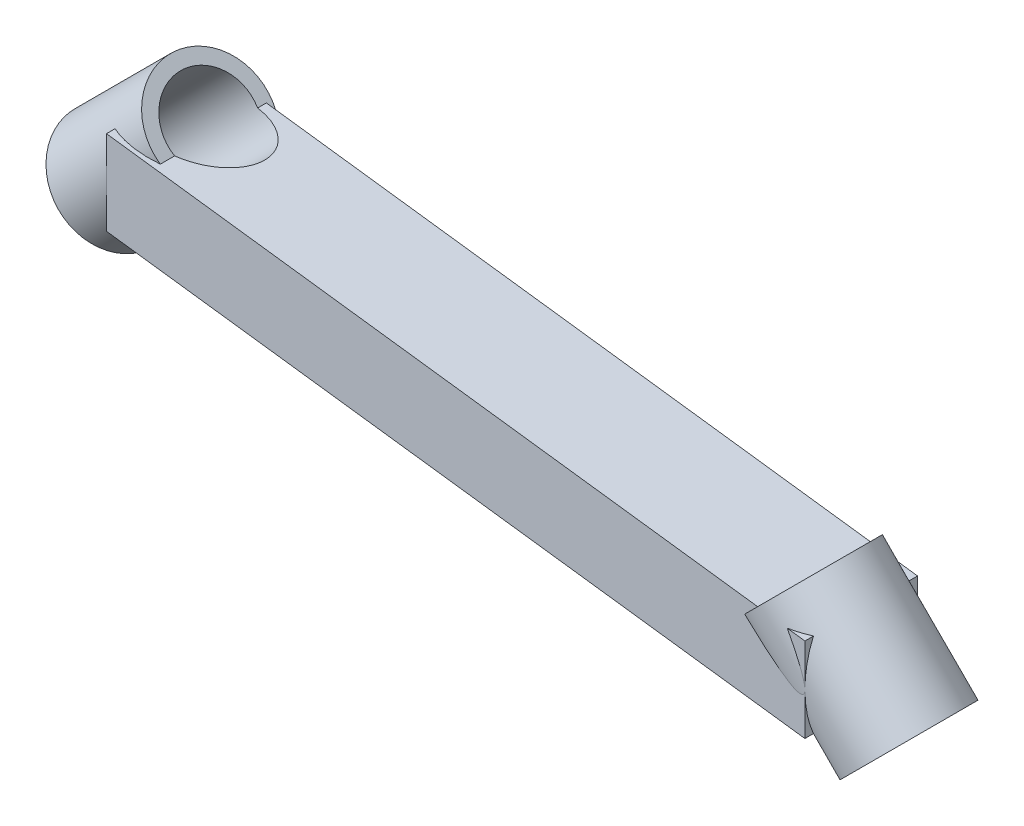
from build123d import *
from build123d.topology import SkipClean

# Parameters (mm, degrees)
BOSS_EXTRUDE1_DEPTH     = 7.5
SKETCH2_R               = 10
BOSS_EXTRUDE2_DEPTH     = 12
SKETCH3_R               = 10
BOSS_EXTRUDE3_DEPTH     = 12
SKETCH4_R               = 7.5
CUT_EXTRUDE1_DEPTH      = 144.04424685
CUT_EXTRUDE1_DEPTH_BACK = 144.04424685


with BuildPart() as part:
    # Sketch1 → Boss-Extrude1 (new, symmetric)
    with BuildSketch(Plane(origin=(0, 0, 0), x_dir=(1, 0, 0), z_dir=(0, 1, 0))):
        Polygon((-70, -2), (-70, 18), (70, 2), (70, -18), align=None)
    extrude(amount=BOSS_EXTRUDE1_DEPTH, both=True)

    # Sketch2 → Boss-Extrude2 (add, symmetric)
    with SkipClean():  # the faces are left unmerged after this step: merging them gives an invalid solid
        with BuildSketch(Plane(origin=(-35, -35, 0), x_dir=(0, 0, 1), z_dir=(-0.7071067811865464, -0.7071067811865488, 0))):
            with Locations(Location((-8, 49.497474683, 0), (0, 0, 147.972239886))):
                Circle(SKETCH2_R)
        extrude(amount=BOSS_EXTRUDE2_DEPTH, both=True)

    # Sketch3 → Boss-Extrude3 (add, symmetric)
    with SkipClean():  # the faces are left unmerged after this step: merging them gives an invalid solid
        with BuildSketch(Plane(origin=(35, -35, 0), x_dir=(0, 0, 1), z_dir=(0.7071067811865512, -0.7071067811865439, 0))):
            with Locations(Location((8, -49.497474683, 0), (0, 0, 147.972239886))):
                Circle(SKETCH3_R)
        extrude(amount=BOSS_EXTRUDE3_DEPTH, both=True)

    # Sketch4 → Cut-Extrude1 (cut, two sides)
    with SkipClean():  # the faces are left unmerged after this step: merging them gives an invalid solid
        with BuildSketch(Plane(origin=(-43.485281374, -43.485281374, 0), x_dir=(0, 0, 1), z_dir=(-0.7071067811865465, -0.7071067811865487, 0))) as cut_extrude1_sk:
            with Locations(Location((-8, 49.497474683, 0), (0, 0, 270))):
                Circle(SKETCH4_R)
        extrude(amount=CUT_EXTRUDE1_DEPTH, mode=Mode.SUBTRACT)
        extrude(cut_extrude1_sk.sketch, amount=-CUT_EXTRUDE1_DEPTH_BACK, mode=Mode.SUBTRACT)


solid = part.part
